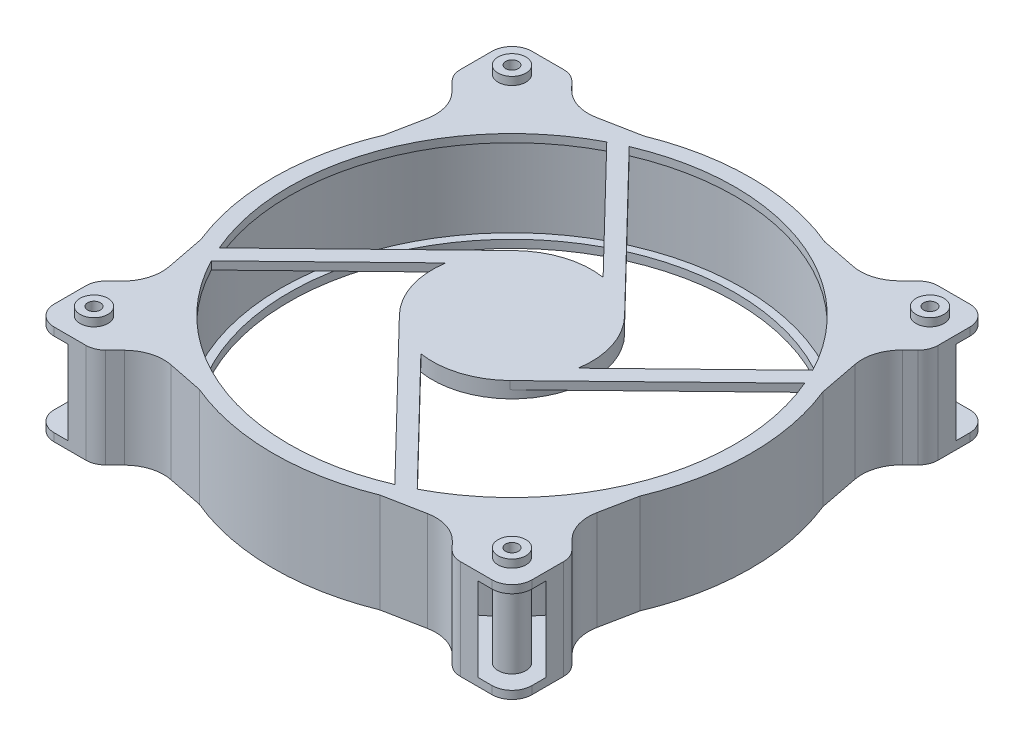
from build123d import *

# Parameters (mm, degrees)
SKETCH1_R               = 60
BOSS_EXTRUDE1_DEPTH     = 2
BOSS_EXTRUDE2_DEPTH     = 21
BOSS_EXTRUDE3_DEPTH     = 2
SKETCH4_W               = 12
SKETCH4_H               = 21
CUT_EXTRUDE1_DEPTH      = 32
CIRPATTERN1_COUNT       = 4
CUT_EXTRUDE2_DEPTH      = 33
SKETCH6_R               = 56
CUT_EXTRUDE5_DEPTH      = 23
SKETCH7_R               = 20
SKETCH7_R_2             = 18
BOSS_EXTRUDE4_DEPTH     = 2
BOSS_EXTRUDE5_DEPTH     = 21
BOSS_EXTRUDE7_DEPTH     = 14.5
CUT_EXTRUDE6_DEPTH      = 15.5
CUT_EXTRUDE6_DEPTH_BACK = 15.5


with BuildPart() as part:
    # Sketch1 → Boss-Extrude1 (new body)
    with BuildSketch(Plane(origin=(0, 0, 0), x_dir=(1, 0, 0), z_dir=(0, 1, 0))):
        with BuildLine():
            ThreePointArc((-23.173209062, -55.344397926), (-42.70849241, -42.1424332), (-55.648645322, -22.432750029))
            Line((-55.648645322, -22.432750029), (-53.693881634, -32.467551669))
            ThreePointArc((-53.693881634, -32.467551669), (-53.962154912, -37.354561343), (-56.517451068, -41.528923051))
            Line((-56.517451068, -41.528923051), (-58.495966442, -43.463880981))
            ThreePointArc((-58.495966442, -43.463880981), (-59.608678347, -45.099450835), (-60, -47.038544411))
            Line((-60, -47.038544411), (-60, -55))
            ThreePointArc((-60, -55), (-58.535533906, -58.535533906), (-55, -60))
            Line((-55, -60), (-47.038544411, -60))
            ThreePointArc((-47.038544411, -60), (-45.150862916, -59.629973928), (-43.542577969, -58.57466343))
            Line((-43.542577969, -58.57466343), (-41.110320096, -56.195952239))
            ThreePointArc((-41.110320096, -56.195952239), (-36.958755059, -53.757145262), (-32.148699827, -53.541181405))
            Line((-32.148699827, -53.541181405), (-23.173209062, -55.344397926))
        make_face()
        with BuildLine():
            Line((-60, 55), (-60, 47.038544411))
            ThreePointArc((-60, 47.038544411), (-59.629973928, 45.150862916), (-58.57466343, 43.542577969))
            Line((-58.57466343, 43.542577969), (-56.195952239, 41.110320096))
            ThreePointArc((-56.195952239, 41.110320096), (-53.757145262, 36.958755059), (-53.541181405, 32.148699827))
            Line((-53.541181405, 32.148699827), (-55.344397926, 23.173209062))
            ThreePointArc((-55.344397926, 23.173209062), (-42.1424332, 42.70849241), (-22.432750029, 55.648645322))
            Line((-22.432750029, 55.648645322), (-32.467551669, 53.693881634))
            ThreePointArc((-32.467551669, 53.693881634), (-37.354561343, 53.962154912), (-41.528923051, 56.517451068))
            Line((-41.528923051, 56.517451068), (-43.463880981, 58.495966442))
            ThreePointArc((-43.463880981, 58.495966442), (-45.099450835, 59.608678347), (-47.038544411, 60))
            Line((-47.038544411, 60), (-55, 60))
            ThreePointArc((-55, 60), (-58.535533906, 58.535533906), (-60, 55))
        make_face()
        with BuildLine():
            Line((32.148699827, 53.541181405), (23.173209062, 55.344397926))
            ThreePointArc((23.173209062, 55.344397926), (42.70849241, 42.1424332), (55.648645322, 22.432750029))
            Line((55.648645322, 22.432750029), (53.693881634, 32.467551669))
            ThreePointArc((53.693881634, 32.467551669), (53.962154912, 37.354561343), (56.517451068, 41.528923051))
            Line((56.517451068, 41.528923051), (58.495966442, 43.463880981))
            ThreePointArc((58.495966442, 43.463880981), (59.608678347, 45.099450835), (60, 47.038544411))
            Line((60, 47.038544411), (60, 55))
            ThreePointArc((60, 55), (58.535533906, 58.535533906), (55, 60))
            Line((55, 60), (47.038544411, 60))
            ThreePointArc((47.038544411, 60), (45.150862916, 59.629973928), (43.542577969, 58.57466343))
            Line((43.542577969, 58.57466343), (41.110320096, 56.195952239))
            ThreePointArc((41.110320096, 56.195952239), (36.958755059, 53.757145262), (32.148699827, 53.541181405))
        make_face()
        with BuildLine():
            ThreePointArc((55.344397926, -23.173209062), (42.1424332, -42.70849241), (22.432750029, -55.648645322))
            Line((22.432750029, -55.648645322), (32.467551669, -53.693881634))
            ThreePointArc((32.467551669, -53.693881634), (37.354561343, -53.962154912), (41.528923051, -56.517451068))
            Line((41.528923051, -56.517451068), (43.463880981, -58.495966442))
            ThreePointArc((43.463880981, -58.495966442), (45.099450835, -59.608678347), (47.038544411, -60))
            Line((47.038544411, -60), (55, -60))
            ThreePointArc((55, -60), (58.535533906, -58.535533906), (60, -55))
            Line((60, -55), (60, -47.038544411))
            ThreePointArc((60, -47.038544411), (59.629973928, -45.150862916), (58.57466343, -43.542577969))
            Line((58.57466343, -43.542577969), (56.195952239, -41.110320096))
            ThreePointArc((56.195952239, -41.110320096), (53.757145262, -36.958755059), (53.541181405, -32.148699827))
            Line((53.541181405, -32.148699827), (55.344397926, -23.173209062))
        make_face()
        Circle(SKETCH1_R)
    extrude(amount=BOSS_EXTRUDE1_DEPTH)

    # Sketch2 → Boss-Extrude2 (add)
    with BuildSketch(Plane(origin=(0, 2, 0), x_dir=(1, 0, 0), z_dir=(0, 1, 0))):
        with BuildLine():
            Line((53.541181405, -32.148699827), (55.344397926, -23.173209062))
            ThreePointArc((55.344397926, -23.173209062), (59.998664889, -0.400264306), (55.648645322, 22.432750029))
            Line((55.648645322, 22.432750029), (53.693881634, 32.467551669))
            ThreePointArc((53.693881634, 32.467551669), (53.962154912, 37.354561343), (56.517451068, 41.528923051))
            Line((56.517451068, 41.528923051), (58.495966442, 43.463880981))
            ThreePointArc((58.495966442, 43.463880981), (59.608678347, 45.099450835), (60, 47.038544411))
            Line((60, 47.038544411), (60, 55))
            ThreePointArc((60, 55), (58.535533906, 58.535533906), (55, 60))
            Line((55, 60), (47.038544411, 60))
            ThreePointArc((47.038544411, 60), (45.150862916, 59.629973928), (43.542577969, 58.57466343))
            Line((43.542577969, 58.57466343), (41.110320096, 56.195952239))
            ThreePointArc((41.110320096, 56.195952239), (36.958755059, 53.757145262), (32.148699827, 53.541181405))
            Line((32.148699827, 53.541181405), (23.173209062, 55.344397926))
            ThreePointArc((23.173209062, 55.344397926), (0.400264306, 59.998664889), (-22.432750029, 55.648645322))
            Line((-22.432750029, 55.648645322), (-32.467551669, 53.693881634))
            ThreePointArc((-32.467551669, 53.693881634), (-37.354561343, 53.962154912), (-41.528923051, 56.517451068))
            Line((-41.528923051, 56.517451068), (-43.463880981, 58.495966442))
            ThreePointArc((-43.463880981, 58.495966442), (-45.099450835, 59.608678347), (-47.038544411, 60))
            Line((-47.038544411, 60), (-55, 60))
            ThreePointArc((-55, 60), (-58.535533906, 58.535533906), (-60, 55))
            Line((-60, 55), (-60, 47.038544411))
            ThreePointArc((-60, 47.038544411), (-59.629973928, 45.150862916), (-58.57466343, 43.542577969))
            Line((-58.57466343, 43.542577969), (-56.195952239, 41.110320096))
            ThreePointArc((-56.195952239, 41.110320096), (-53.757145262, 36.958755059), (-53.541181405, 32.148699827))
            Line((-53.541181405, 32.148699827), (-55.344397926, 23.173209062))
            ThreePointArc((-55.344397926, 23.173209062), (-59.998664889, 0.400264306), (-55.648645322, -22.432750029))
            Line((-55.648645322, -22.432750029), (-53.693881634, -32.467551669))
            ThreePointArc((-53.693881634, -32.467551669), (-53.962154912, -37.354561343), (-56.517451068, -41.528923051))
            Line((-56.517451068, -41.528923051), (-58.495966442, -43.463880981))
            ThreePointArc((-58.495966442, -43.463880981), (-59.608678347, -45.099450835), (-60, -47.038544411))
            Line((-60, -47.038544411), (-60, -55))
            ThreePointArc((-60, -55), (-58.535533906, -58.535533906), (-55, -60))
            Line((-55, -60), (-47.038544411, -60))
            ThreePointArc((-47.038544411, -60), (-45.150862916, -59.629973928), (-43.542577969, -58.57466343))
            Line((-43.542577969, -58.57466343), (-41.110320096, -56.195952239))
            ThreePointArc((-41.110320096, -56.195952239), (-36.958755059, -53.757145262), (-32.148699827, -53.541181405))
            Line((-32.148699827, -53.541181405), (-23.173209062, -55.344397926))
            ThreePointArc((-23.173209062, -55.344397926), (-0.400264306, -59.998664889), (22.432750029, -55.648645322))
            Line((22.432750029, -55.648645322), (32.467551669, -53.693881634))
            ThreePointArc((32.467551669, -53.693881634), (37.354561343, -53.962154912), (41.528923051, -56.517451068))
            Line((41.528923051, -56.517451068), (43.463880981, -58.495966442))
            ThreePointArc((43.463880981, -58.495966442), (45.099450835, -59.608678347), (47.038544411, -60))
            Line((47.038544411, -60), (55, -60))
            ThreePointArc((55, -60), (58.535533906, -58.535533906), (60, -55))
            Line((60, -55), (60, -47.038544411))
            ThreePointArc((60, -47.038544411), (59.629973928, -45.150862916), (58.57466343, -43.542577969))
            Line((58.57466343, -43.542577969), (56.195952239, -41.110320096))
            ThreePointArc((56.195952239, -41.110320096), (53.757145262, -36.958755059), (53.541181405, -32.148699827))
        make_face()
        with BuildLine():
            Line((-51.730781171, -32.085142765), (-53.722450556, -21.860885302))
            ThreePointArc((-53.722450556, -21.860885302), (-57.998684338, 0.390659708), (-53.423094251, 22.582581798))
            Line((-53.423094251, 22.582581798), (-51.580361866, 31.75476235))
            ThreePointArc((-51.580361866, 31.75476235), (-51.839518494, 37.526828629), (-54.766086867, 42.508706672))
            Line((-54.766086867, 42.508706672), (-57.144798058, 44.940964546))
            ThreePointArc((-57.144798058, 44.940964546), (-57.777984357, 45.905935514), (-58, 47.038544411))
            Line((-58, 47.038544411), (-58, 55))
            ThreePointArc((-58, 55), (-57.121320344, 57.121320344), (-55, 58))
            Line((-55, 58), (-47.038544411, 58))
            ThreePointArc((-47.038544411, 58), (-45.875088265, 57.765207008), (-44.893746353, 57.097579865))
            Line((-44.893746353, 57.097579865), (-42.958788423, 55.119064492))
            ThreePointArc((-42.958788423, 55.119064492), (-37.949554374, 52.052709104), (-32.085142765, 51.730781171))
            Line((-32.085142765, 51.730781171), (-21.860885302, 53.722450556))
            ThreePointArc((-21.860885302, 53.722450556), (0.390659708, 57.998684338), (22.582581798, 53.423094251))
            Line((22.582581798, 53.423094251), (31.75476235, 51.580361866))
            ThreePointArc((31.75476235, 51.580361866), (37.526828629, 51.839518494), (42.508706672, 54.766086867))
            Line((42.508706672, 54.766086867), (44.940964546, 57.144798058))
            ThreePointArc((44.940964546, 57.144798058), (45.905935514, 57.777984357), (47.038544411, 58))
            Line((47.038544411, 58), (55, 58))
            ThreePointArc((55, 58), (57.121320344, 57.121320344), (58, 55))
            Line((58, 55), (58, 47.038544411))
            ThreePointArc((58, 47.038544411), (57.765207008, 45.875088265), (57.097579865, 44.893746353))
            Line((57.097579865, 44.893746353), (55.119064492, 42.958788423))
            ThreePointArc((55.119064492, 42.958788423), (52.052709104, 37.949554374), (51.730781171, 32.085142765))
            Line((51.730781171, 32.085142765), (53.722450556, 21.860885302))
            ThreePointArc((53.722450556, 21.860885302), (57.998684338, -0.390659708), (53.423094251, -22.582581798))
            Line((53.423094251, -22.582581798), (51.580361866, -31.75476235))
            ThreePointArc((51.580361866, -31.75476235), (51.839518494, -37.526828629), (54.766086867, -42.508706672))
            Line((54.766086867, -42.508706672), (57.144798058, -44.940964546))
            ThreePointArc((57.144798058, -44.940964546), (57.777984357, -45.905935514), (58, -47.038544411))
            Line((58, -47.038544411), (58, -55))
            ThreePointArc((58, -55), (57.121320344, -57.121320344), (55, -58))
            Line((55, -58), (47.038544411, -58))
            ThreePointArc((47.038544411, -58), (45.875088265, -57.765207008), (44.893746353, -57.097579865))
            Line((44.893746353, -57.097579865), (42.958788423, -55.119064492))
            ThreePointArc((42.958788423, -55.119064492), (37.949554374, -52.052709104), (32.085142765, -51.730781171))
            Line((32.085142765, -51.730781171), (21.860885302, -53.722450556))
            ThreePointArc((21.860885302, -53.722450556), (-0.390659708, -57.998684338), (-22.582581798, -53.423094251))
            Line((-22.582581798, -53.423094251), (-31.75476235, -51.580361866))
            ThreePointArc((-31.75476235, -51.580361866), (-37.526828629, -51.839518494), (-42.508706672, -54.766086867))
            Line((-42.508706672, -54.766086867), (-44.940964546, -57.144798058))
            ThreePointArc((-44.940964546, -57.144798058), (-45.905935514, -57.777984357), (-47.038544411, -58))
            Line((-47.038544411, -58), (-55, -58))
            ThreePointArc((-55, -58), (-57.121320344, -57.121320344), (-58, -55))
            Line((-58, -55), (-58, -47.038544411))
            ThreePointArc((-58, -47.038544411), (-57.765207008, -45.875088265), (-57.097579865, -44.893746353))
            Line((-57.097579865, -44.893746353), (-55.119064492, -42.958788423))
            ThreePointArc((-55.119064492, -42.958788423), (-52.052709104, -37.949554374), (-51.730781171, -32.085142765))
        make_face(mode=Mode.SUBTRACT)
    extrude(amount=BOSS_EXTRUDE2_DEPTH)

    # Sketch3 → Boss-Extrude3 (add)
    with BuildSketch(Plane(origin=(0, 23, 0), x_dir=(1, 0, 0), z_dir=(0, 1, 0))):
        with BuildLine():
            Line((-55.648645322, -22.432750029), (-53.693881634, -32.467551669))
            ThreePointArc((-53.693881634, -32.467551669), (-53.962154912, -37.354561343), (-56.517451068, -41.528923051))
            Line((-56.517451068, -41.528923051), (-58.495966442, -43.463880981))
            ThreePointArc((-58.495966442, -43.463880981), (-59.608678347, -45.099450835), (-60, -47.038544411))
            Line((-60, -47.038544411), (-60, -55))
            ThreePointArc((-60, -55), (-58.535533906, -58.535533906), (-55, -60))
            Line((-55, -60), (-47.038544411, -60))
            ThreePointArc((-47.038544411, -60), (-45.150862916, -59.629973928), (-43.542577969, -58.57466343))
            Line((-43.542577969, -58.57466343), (-41.110320096, -56.195952239))
            ThreePointArc((-41.110320096, -56.195952239), (-36.958755059, -53.757145262), (-32.148699827, -53.541181405))
            Line((-32.148699827, -53.541181405), (-23.173209062, -55.344397926))
            ThreePointArc((-23.173209062, -55.344397926), (-0.400264306, -59.998664889), (22.432750029, -55.648645322))
            Line((22.432750029, -55.648645322), (32.467551669, -53.693881634))
            ThreePointArc((32.467551669, -53.693881634), (37.354561343, -53.962154912), (41.528923051, -56.517451068))
            Line((41.528923051, -56.517451068), (43.463880981, -58.495966442))
            ThreePointArc((43.463880981, -58.495966442), (45.099450835, -59.608678347), (47.038544411, -60))
            Line((47.038544411, -60), (55, -60))
            ThreePointArc((55, -60), (58.535533906, -58.535533906), (60, -55))
            Line((60, -55), (60, -47.038544411))
            ThreePointArc((60, -47.038544411), (59.629973928, -45.150862916), (58.57466343, -43.542577969))
            Line((58.57466343, -43.542577969), (56.195952239, -41.110320096))
            ThreePointArc((56.195952239, -41.110320096), (53.757145262, -36.958755059), (53.541181405, -32.148699827))
            Line((53.541181405, -32.148699827), (55.344397926, -23.173209062))
            ThreePointArc((55.344397926, -23.173209062), (59.998664889, -0.400264306), (55.648645322, 22.432750029))
            Line((55.648645322, 22.432750029), (53.693881634, 32.467551669))
            ThreePointArc((53.693881634, 32.467551669), (53.962154912, 37.354561343), (56.517451068, 41.528923051))
            Line((56.517451068, 41.528923051), (58.495966442, 43.463880981))
            ThreePointArc((58.495966442, 43.463880981), (59.608678347, 45.099450835), (60, 47.038544411))
            Line((60, 47.038544411), (60, 55))
            ThreePointArc((60, 55), (58.535533906, 58.535533906), (55, 60))
            Line((55, 60), (47.038544411, 60))
            ThreePointArc((47.038544411, 60), (45.150862916, 59.629973928), (43.542577969, 58.57466343))
            Line((43.542577969, 58.57466343), (41.110320096, 56.195952239))
            ThreePointArc((41.110320096, 56.195952239), (36.958755059, 53.757145262), (32.148699827, 53.541181405))
            Line((32.148699827, 53.541181405), (23.173209062, 55.344397926))
            ThreePointArc((23.173209062, 55.344397926), (0.400264306, 59.998664889), (-22.432750029, 55.648645322))
            Line((-22.432750029, 55.648645322), (-32.467551669, 53.693881634))
            ThreePointArc((-32.467551669, 53.693881634), (-37.354561343, 53.962154912), (-41.528923051, 56.517451068))
            Line((-41.528923051, 56.517451068), (-43.463880981, 58.495966442))
            ThreePointArc((-43.463880981, 58.495966442), (-45.099450835, 59.608678347), (-47.038544411, 60))
            Line((-47.038544411, 60), (-55, 60))
            ThreePointArc((-55, 60), (-58.535533906, 58.535533906), (-60, 55))
            Line((-60, 55), (-60, 47.038544411))
            ThreePointArc((-60, 47.038544411), (-59.629973928, 45.150862916), (-58.57466343, 43.542577969))
            Line((-58.57466343, 43.542577969), (-56.195952239, 41.110320096))
            ThreePointArc((-56.195952239, 41.110320096), (-53.757145262, 36.958755059), (-53.541181405, 32.148699827))
            Line((-53.541181405, 32.148699827), (-55.344397926, 23.173209062))
            ThreePointArc((-55.344397926, 23.173209062), (-59.998664889, 0.400264306), (-55.648645322, -22.432750029))
        make_face()
    extrude(amount=BOSS_EXTRUDE3_DEPTH)

    # Sketch4 → Cut-Extrude1 (cut)
    with BuildSketch(Plane(origin=(-53.519272205, 0, 53.519272205), x_dir=(0.707106781, 0, 0.707106781), z_dir=(-0.707106781, 0, 0.707106781))):
        with Locations((0, 12.5)):
            Rectangle(SKETCH4_W, SKETCH4_H)
    cut_extrude1 = extrude(amount=CUT_EXTRUDE1_DEPTH, mode=Mode.SUBTRACT)

    # CirPattern1: Cut-Extrude1 ×4 about axis
    cirpattern1_axis = Axis((0, 0, 0), (0, 1, 0))
    for i in range(1, CIRPATTERN1_COUNT):
        add(cut_extrude1.rotate(cirpattern1_axis, i * 360 / CIRPATTERN1_COUNT), mode=Mode.SUBTRACT)

    # Sketch5 → Cut-Extrude2 (cut)
    with BuildSketch(Plane(origin=(0, 25, 0), x_dir=(1, 0, 0), z_dir=(0, 1, 0))):
        with BuildLine():
            ThreePointArc((14.360737172, 13.920101576), (19.069892572, 6.028200169), (19.752523473, -3.136529365))
            Line((19.752523473, -3.136529365), (49.669983439, 25.862960873))
            ThreePointArc((49.669983439, 25.862960873), (18.836684093, 52.736887777), (-22.045050965, 51.478303468))
            Line((-22.045050965, 51.478303468), (14.360737172, 13.920101576))
        make_face()
        with BuildLine():
            Line((51.478303468, 22.045050965), (13.920100849, -14.360737876))
            ThreePointArc((13.920100849, -14.360737876), (6.028199687, -19.069892725), (-3.136529365, -19.752523473))
            Line((-3.136529365, -19.752523473), (25.862960873, -49.669983439))
            ThreePointArc((25.862960873, -49.669983439), (52.736887777, -18.836684093), (51.478303468, 22.045050965))
        make_face()
        with BuildLine():
            Line((3.136529365, 19.752523473), (-25.862960873, 49.669983439))
            ThreePointArc((-25.862960873, 49.669983439), (-52.736887777, 18.836684093), (-51.478303468, -22.045050965))
            Line((-51.478303468, -22.045050965), (-13.920101492, 14.360737253))
            ThreePointArc((-13.920101492, 14.360737253), (-6.028200114, 19.06989259), (3.136529365, 19.752523473))
        make_face()
        with BuildLine():
            Line((22.045050965, -51.478303468), (-14.360737876, -13.920100849))
            ThreePointArc((-14.360737876, -13.920100849), (-19.069892725, -6.028199687), (-19.752523473, 3.136529365))
            Line((-19.752523473, 3.136529365), (-49.669983439, -25.862960873))
            ThreePointArc((-49.669983439, -25.862960873), (-18.836684093, -52.736887777), (22.045050965, -51.478303468))
        make_face()
    extrude(amount=-CUT_EXTRUDE2_DEPTH, mode=Mode.SUBTRACT)

    # Sketch6 → Cut-Extrude5 (cut)
    with BuildSketch(Plane.XZ):
        Circle(SKETCH6_R)
    extrude(amount=-CUT_EXTRUDE5_DEPTH, mode=Mode.SUBTRACT)

    # Sketch7 → Boss-Extrude4 (add)
    with BuildSketch(Plane.XZ.offset(-23)):
        Circle(SKETCH7_R)
        Circle(SKETCH7_R_2, mode=Mode.SUBTRACT)
    extrude(amount=BOSS_EXTRUDE4_DEPTH)

    # Sketch8 → Boss-Extrude5 (add)
    with BuildSketch(Plane(origin=(0, 2, 0), x_dir=(1, 0, 0), z_dir=(0, 1, 0))):
        with BuildLine():
            ThreePointArc((-52.227709412, -29.534155982), (-42.646498651, -42.205167371), (-30.075837881, -51.917665354))
            Line((-30.075837881, -51.917665354), (-22.582581798, -53.423094251))
            ThreePointArc((-22.582581798, -53.423094251), (-41.287501124, -40.735024867), (-53.722450556, -21.860885302))
            Line((-53.722450556, -21.860885302), (-52.227709412, -29.534155982))
        make_face()
        with BuildLine():
            Line((21.860885302, -53.722450556), (29.534155982, -52.227709412))
            ThreePointArc((29.534155982, -52.227709412), (42.205167371, -42.646498651), (51.917665354, -30.075837881))
            Line((51.917665354, -30.075837881), (53.423094251, -22.582581798))
            ThreePointArc((53.423094251, -22.582581798), (40.735024867, -41.287501124), (21.860885302, -53.722450556))
        make_face()
        with BuildLine():
            ThreePointArc((52.227709412, 29.534155982), (42.646498651, 42.205167371), (30.075837881, 51.917665354))
            Line((30.075837881, 51.917665354), (22.582581798, 53.423094251))
            ThreePointArc((22.582581798, 53.423094251), (41.287501124, 40.735024867), (53.722450556, 21.860885302))
            Line((53.722450556, 21.860885302), (52.227709412, 29.534155982))
        make_face()
        with BuildLine():
            ThreePointArc((-29.534155982, 52.227709412), (-42.205167371, 42.646498651), (-51.917665354, 30.075837881))
            Line((-51.917665354, 30.075837881), (-53.423094251, 22.582581798))
            ThreePointArc((-53.423094251, 22.582581798), (-40.735024867, 41.287501124), (-21.860885302, 53.722450556))
            Line((-21.860885302, 53.722450556), (-29.534155982, 52.227709412))
        make_face()
    extrude(amount=BOSS_EXTRUDE5_DEPTH)

    # Sketch10 → Boss-Extrude7 (add, symmetric)
    with BuildSketch(Plane(origin=(0, 12.5, 0), x_dir=(1, 0, 0), z_dir=(0, 1, 0))):
        with BuildLine():
            ThreePointArc((-49, 52.5), (-54.974873734, 54.974873734), (-52.5, 49))
            Line((-52.5, 49), (-52.5, 50.9))
            ThreePointArc((-52.5, 50.9), (-53.63137085, 53.63137085), (-50.9, 52.5))
            Line((-50.9, 52.5), (-49, 52.5))
        make_face()
        with BuildLine():
            Line((-52.5, 50.9), (-52.5, 49))
            ThreePointArc((-52.5, 49), (-50.025126266, 50.025126266), (-49, 52.5))
            Line((-49, 52.5), (-50.9, 52.5))
            ThreePointArc((-50.9, 52.5), (-51.36862915, 51.36862915), (-52.5, 50.9))
        make_face()
        with BuildLine():
            ThreePointArc((49, 52.5), (50.025126266, 50.025126266), (52.5, 49))
            Line((52.5, 49), (52.5, 50.9))
            ThreePointArc((52.5, 50.9), (51.36862915, 51.36862915), (50.9, 52.5))
            Line((50.9, 52.5), (49, 52.5))
        make_face()
        with BuildLine():
            Line((52.5, 50.9), (52.5, 49))
            ThreePointArc((52.5, 49), (54.974873734, 50.025126266), (56, 52.5))
            ThreePointArc((56, 52.5), (52.5, 56), (49, 52.5))
            Line((49, 52.5), (50.9, 52.5))
            ThreePointArc((50.9, 52.5), (52.5, 54.1), (54.1, 52.5))
            ThreePointArc((54.1, 52.5), (53.63137085, 51.36862915), (52.5, 50.9))
        make_face()
        with BuildLine():
            ThreePointArc((52.5, -49), (50.025126266, -50.025126266), (49, -52.5))
            Line((49, -52.5), (50.9, -52.5))
            ThreePointArc((50.9, -52.5), (51.36862915, -51.36862915), (52.5, -50.9))
            Line((52.5, -50.9), (52.5, -49))
        make_face()
        with BuildLine():
            Line((50.9, -52.5), (49, -52.5))
            ThreePointArc((49, -52.5), (52.5, -56), (56, -52.5))
            ThreePointArc((56, -52.5), (54.974873734, -50.025126266), (52.5, -49))
            Line((52.5, -49), (52.5, -50.9))
            ThreePointArc((52.5, -50.9), (53.63137085, -51.36862915), (54.1, -52.5))
            ThreePointArc((54.1, -52.5), (52.5, -54.1), (50.9, -52.5))
        make_face()
        with BuildLine():
            ThreePointArc((-52.5, -50.9), (-51.36862915, -51.36862915), (-50.9, -52.5))
            Line((-50.9, -52.5), (-49, -52.5))
            ThreePointArc((-49, -52.5), (-50.025126266, -50.025126266), (-52.5, -49))
            Line((-52.5, -49), (-52.5, -50.9))
        make_face()
        with BuildLine():
            Line((-49, -52.5), (-50.9, -52.5))
            ThreePointArc((-50.9, -52.5), (-53.63137085, -53.63137085), (-52.5, -50.9))
            Line((-52.5, -50.9), (-52.5, -49))
            ThreePointArc((-52.5, -49), (-54.974873734, -54.974873734), (-49, -52.5))
        make_face()
    extrude(amount=BOSS_EXTRUDE7_DEPTH, both=True)

    # Sketch10_3 → Cut-Extrude6 (cut, two sides)
    with BuildSketch(Plane(origin=(0, 12.5, 0), x_dir=(1, 0, 0), z_dir=(0, 1, 0))) as cut_extrude6_sk:
        with BuildLine():
            ThreePointArc((-50.9, 52.5), (-53.63137085, 53.63137085), (-52.5, 50.9))
            Line((-52.5, 50.9), (-52.5, 52.5))
            Line((-52.5, 52.5), (-50.9, 52.5))
        make_face()
        with BuildLine():
            Line((-52.5, 52.5), (-52.5, 50.9))
            ThreePointArc((-52.5, 50.9), (-51.36862915, 51.36862915), (-50.9, 52.5))
            Line((-50.9, 52.5), (-52.5, 52.5))
        make_face()
        with BuildLine():
            ThreePointArc((50.9, 52.5), (51.36862915, 51.36862915), (52.5, 50.9))
            Line((52.5, 50.9), (52.5, 52.5))
            Line((52.5, 52.5), (50.9, 52.5))
        make_face()
        with BuildLine():
            Line((52.5, 52.5), (52.5, 50.9))
            ThreePointArc((52.5, 50.9), (53.63137085, 51.36862915), (54.1, 52.5))
            ThreePointArc((54.1, 52.5), (52.5, 54.1), (50.9, 52.5))
            Line((50.9, 52.5), (52.5, 52.5))
        make_face()
        with BuildLine():
            ThreePointArc((52.5, -50.9), (51.36862915, -51.36862915), (50.9, -52.5))
            Line((50.9, -52.5), (52.5, -52.5))
            Line((52.5, -52.5), (52.5, -50.9))
        make_face()
        with BuildLine():
            Line((52.5, -52.5), (50.9, -52.5))
            ThreePointArc((50.9, -52.5), (52.5, -54.1), (54.1, -52.5))
            ThreePointArc((54.1, -52.5), (53.63137085, -51.36862915), (52.5, -50.9))
            Line((52.5, -50.9), (52.5, -52.5))
        make_face()
        with BuildLine():
            Line((-52.5, -50.9), (-52.5, -52.5))
            Line((-52.5, -52.5), (-50.9, -52.5))
            ThreePointArc((-50.9, -52.5), (-51.36862915, -51.36862915), (-52.5, -50.9))
        make_face()
        with BuildLine():
            Line((-50.9, -52.5), (-52.5, -52.5))
            Line((-52.5, -52.5), (-52.5, -50.9))
            ThreePointArc((-52.5, -50.9), (-53.63137085, -53.63137085), (-50.9, -52.5))
        make_face()
    extrude(amount=CUT_EXTRUDE6_DEPTH, mode=Mode.SUBTRACT)
    extrude(cut_extrude6_sk.sketch, amount=-CUT_EXTRUDE6_DEPTH_BACK, mode=Mode.SUBTRACT)


solid = part.part
